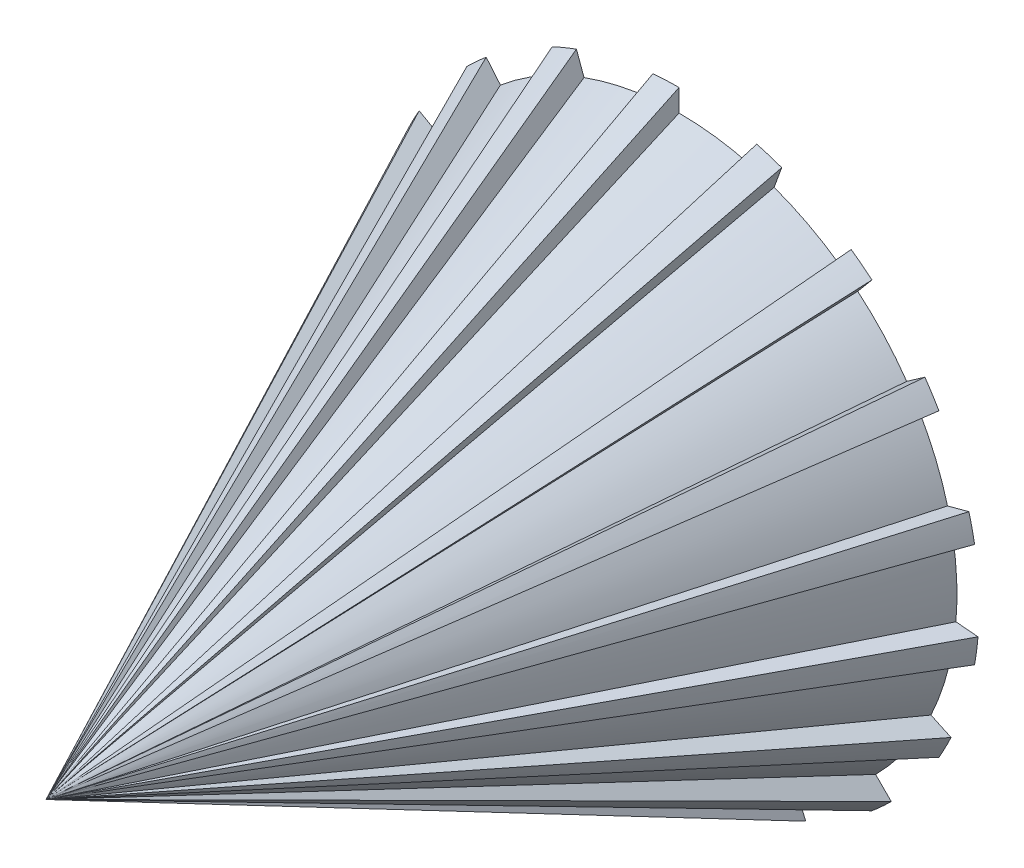
from build123d import *
from build123d.topology import SkipClean

# Parameters (mm, degrees)
SKETCH1_R           = 15
BOSS_EXTRUDE1_DEPTH = 2
CUT_EXTRUDE1_START  = 10
CUT_EXTRUDE1_DEPTH  = 10


with BuildPart() as part:
    # Sketch1 → Boss-Extrude1 (new body)
    with BuildSketch(Plane.XY):
        Circle(SKETCH1_R)
        with BuildLine():
            ThreePointArc((5.499090834, 5.1), (0, -7.5), (-5.499090834, 5.1))
            Line((-5.499090834, 5.1), (5.499090834, 5.1))
        make_face(mode=Mode.SUBTRACT)
    extrude(amount=-BOSS_EXTRUDE1_DEPTH)

    # Sketch3 → Loft2 section 0
    with BuildSketch(Plane.XY, mode=Mode.PRIVATE) as loft2_s0:
        with BuildLine():
            Line((0, 47.4), (0, 43.9))
            ThreePointArc((0, 43.9), (5.730099838, 43.524429414), (11.36215608, 42.404143774))
            Line((11.36215608, 42.404143774), (12.268022738, 45.784884166))
            ThreePointArc((12.268022738, 45.784884166), (14.253454897, 45.206183465), (16.211754794, 44.541430225))
            Line((16.211754794, 44.541430225), (15.014684292, 41.252506053))
            ThreePointArc((15.014684292, 41.252506053), (20.270764121, 38.939775577), (25.180005556, 35.960774744))
            Line((25.180005556, 35.960774744), (27.187523083, 38.827806899))
            ThreePointArc((27.187523083, 38.827806899), (28.855291735, 37.60494833), (30.468132699, 36.310506604))
            Line((30.468132699, 36.310506604), (28.218376065, 33.629351053))
            ThreePointArc((28.218376065, 33.629351053), (32.366475086, 29.658410114), (35.960774744, 25.180005556))
            Line((35.960774744, 25.180005556), (38.827806899, 27.187523083))
            ThreePointArc((38.827806899, 27.187523083), (39.976754532, 25.468001436), (41.049604139, 23.7))
            Line((41.049604139, 23.7), (38.018515226, 21.95))
            ThreePointArc((38.018515226, 21.95), (40.558311477, 16.799802681), (42.404143774, 11.36215608))
            Line((42.404143774, 11.36215608), (45.784884166, 12.268022738))
            ThreePointArc((45.784884166, 12.268022738), (46.276430737, 10.259237701), (46.679887493, 8.230923621))
            Line((46.679887493, 8.230923621), (43.233060357, 7.623155))
            ThreePointArc((43.233060357, 7.623155), (43.858216927, 1.914891105), (43.732947246, -3.826137107))
            Line((43.732947246, -3.826137107), (47.21962869, -4.131182206))
            ThreePointArc((47.21962869, -4.131182206), (46.994486429, -6.186941511), (46.679887493, -8.230923621))
            Line((46.679887493, -8.230923621), (43.233060357, -7.623155))
            ThreePointArc((43.233060357, -7.623155), (41.868174138, -13.200984598), (39.786911851, -18.55294169))
            Line((39.786911851, -18.55294169), (42.958989106, -20.032105607))
            ThreePointArc((42.958989106, -20.032105607), (42.044313493, -21.886884267), (41.049604139, -23.7))
            Line((41.049604139, -23.7), (38.018515226, -21.95))
            ThreePointArc((38.018515226, -21.95), (34.828211639, -26.724626733), (31.041987694, -31.041987694))
            Line((31.041987694, -31.041987694), (33.516861428, -33.516861428))
            ThreePointArc((33.516861428, -33.516861428), (32.022975841, -34.946945765), (30.468132699, -36.310506604))
            Line((30.468132699, -36.310506604), (28.218376065, -33.629351053))
            ThreePointArc((28.218376065, -33.629351053), (23.587452806, -37.024884471), (18.55294169, -39.786911851))
            Line((18.55294169, -39.786911851), (20.032105607, -42.958989106))
            ThreePointArc((20.032105607, -42.958989106), (18.139194694, -43.791889841), (16.211754794, -44.541430225))
            Line((16.211754794, -44.541430225), (15.014684292, -41.252506053))
            ThreePointArc((15.014684292, -41.252506053), (9.501699052, -42.859394713), (3.826137107, -43.732947246))
            Line((3.826137107, -43.732947246), (4.131182206, -47.21962869))
            ThreePointArc((4.131182206, -47.21962869), (2.067558961, -47.354885703), (0, -47.4))
            Line((0, -47.4), (0, -43.9))
            ThreePointArc((0, -43.9), (-5.730099838, -43.524429414), (-11.36215608, -42.404143774))
            Line((-11.36215608, -42.404143774), (-12.268022738, -45.784884166))
            ThreePointArc((-12.268022738, -45.784884166), (-14.253454897, -45.206183465), (-16.211754794, -44.541430225))
            Line((-16.211754794, -44.541430225), (-15.014684292, -41.252506053))
            ThreePointArc((-15.014684292, -41.252506053), (-20.270764121, -38.939775577), (-25.180005556, -35.960774744))
            Line((-25.180005556, -35.960774744), (-27.187523083, -38.827806899))
            ThreePointArc((-27.187523083, -38.827806899), (-28.855291735, -37.60494833), (-30.468132699, -36.310506604))
            Line((-30.468132699, -36.310506604), (-28.218376065, -33.629351053))
            ThreePointArc((-28.218376065, -33.629351053), (-32.366475086, -29.658410114), (-35.960774744, -25.180005556))
            Line((-35.960774744, -25.180005556), (-38.827806899, -27.187523083))
            ThreePointArc((-38.827806899, -27.187523083), (-39.976754532, -25.468001436), (-41.049604139, -23.7))
            Line((-41.049604139, -23.7), (-38.018515226, -21.95))
            ThreePointArc((-38.018515226, -21.95), (-40.558311477, -16.799802681), (-42.404143774, -11.36215608))
            Line((-42.404143774, -11.36215608), (-45.784884166, -12.268022738))
            ThreePointArc((-45.784884166, -12.268022738), (-46.276430737, -10.259237701), (-46.679887493, -8.230923621))
            Line((-46.679887493, -8.230923621), (-43.233060357, -7.623155))
            ThreePointArc((-43.233060357, -7.623155), (-43.858216927, -1.914891105), (-43.732947246, 3.826137107))
            Line((-43.732947246, 3.826137107), (-47.21962869, 4.131182206))
            ThreePointArc((-47.21962869, 4.131182206), (-46.994486429, 6.186941511), (-46.679887493, 8.230923621))
            Line((-46.679887493, 8.230923621), (-43.233060357, 7.623155))
            ThreePointArc((-43.233060357, 7.623155), (-41.868174138, 13.200984598), (-39.786911851, 18.55294169))
            Line((-39.786911851, 18.55294169), (-42.958989106, 20.032105607))
            ThreePointArc((-42.958989106, 20.032105607), (-42.044313493, 21.886884267), (-41.049604139, 23.7))
            Line((-41.049604139, 23.7), (-38.018515226, 21.95))
            ThreePointArc((-38.018515226, 21.95), (-34.828211639, 26.724626733), (-31.041987694, 31.041987694))
            Line((-31.041987694, 31.041987694), (-33.516861428, 33.516861428))
            ThreePointArc((-33.516861428, 33.516861428), (-32.022975841, 34.946945765), (-30.468132699, 36.310506604))
            Line((-30.468132699, 36.310506604), (-28.218376065, 33.629351053))
            ThreePointArc((-28.218376065, 33.629351053), (-23.587452806, 37.024884471), (-18.55294169, 39.786911851))
            Line((-18.55294169, 39.786911851), (-20.032105607, 42.958989106))
            ThreePointArc((-20.032105607, 42.958989106), (-18.139194694, 43.791889841), (-16.211754794, 44.541430225))
            Line((-16.211754794, 44.541430225), (-15.014684292, 41.252506053))
            ThreePointArc((-15.014684292, 41.252506053), (-9.501699052, 42.859394713), (-3.826137107, 43.732947246))
            Line((-3.826137107, 43.732947246), (-4.131182206, 47.21962869))
            ThreePointArc((-4.131182206, 47.21962869), (-2.067558961, 47.354885703), (0, 47.4))
        make_face()
    loft([loft2_s0.sketch, Vertex(0, 0, 100)])

    # Sketch1_4 → Cut-Extrude1 (cut)
    with SkipClean():  # the faces are left unmerged after this step: merging them gives an invalid solid
        with BuildSketch(Plane.XY.offset(CUT_EXTRUDE1_START)):
            with BuildLine():
                Line((5.499090834, 5.1), (-5.499090834, 5.1))
                ThreePointArc((-5.499090834, 5.1), (0, -7.5), (5.499090834, 5.1))
            make_face()
        extrude(amount=-CUT_EXTRUDE1_DEPTH, mode=Mode.SUBTRACT)


solid = part.part
